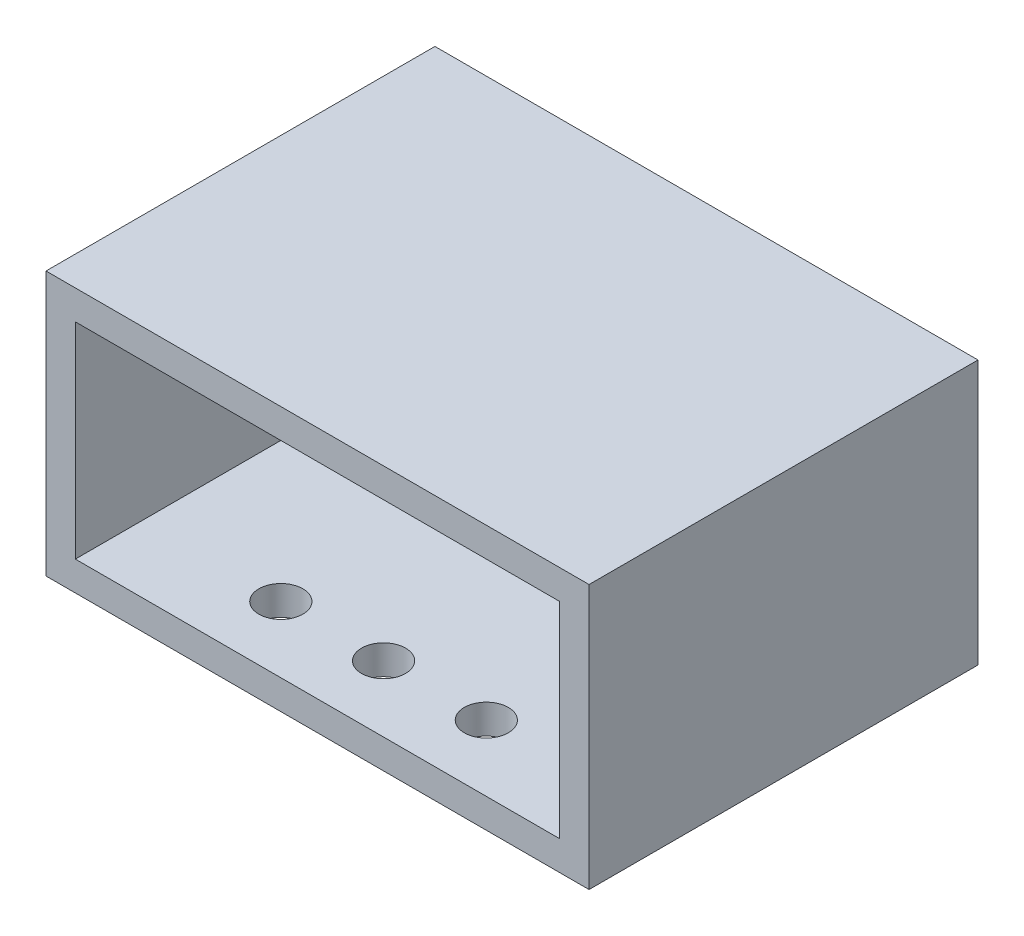
from build123d import *

# Parameters (mm, degrees)
SKIZZE1_W                       = 37
SKIZZE1_H                       = 26.5
AUFSATZ_LINEAR_AUSTRAGEN1_DEPTH = 18
SKIZZE5_W                       = 33
SKIZZE5_H                       = 14
SCHNITT_LINEAR_AUSTRAGEN1_DEPTH = 28
SKIZZE6_R                       = 1.5
SCHNITT_LINEAR_AUSTRAGEN2_DEPTH = 4


with BuildPart() as part:
    # Skizze1 → Aufsatz-Linear austragen1 (new body)
    with BuildSketch(Plane(origin=(0, 0, 0), x_dir=(1, 0, 0), z_dir=(0, 1, 0))):
        Rectangle(SKIZZE1_W, SKIZZE1_H)
    extrude(amount=AUFSATZ_LINEAR_AUSTRAGEN1_DEPTH)

    # Skizze5 → Schnitt-Linear austragen1 (cut)
    with BuildSketch(Plane(origin=(0, 0, -11.25), x_dir=(-1, 0, 0), z_dir=(0, 0, -1))):
        with Locations((0, 9)):
            Rectangle(SKIZZE5_W, SKIZZE5_H)
    extrude(amount=-SCHNITT_LINEAR_AUSTRAGEN1_DEPTH, mode=Mode.SUBTRACT)

    # Skizze6 → Schnitt-Linear austragen2 (cut, symmetric)
    with BuildSketch(Plane.XZ):
        with Locations((-7, 8.75)):
            Circle(SKIZZE6_R)
        with Locations((7, 8.75)):
            Circle(SKIZZE6_R)
        with Locations((0, 8.75)):
            Circle(SKIZZE6_R)
    schnitt_linear_austragen2 = extrude(amount=SCHNITT_LINEAR_AUSTRAGEN2_DEPTH, both=True, mode=Mode.SUBTRACT)

    # Spiegeln1: Schnitt-Linear austragen2 across plane
    add(schnitt_linear_austragen2.mirror(Plane.XY), mode=Mode.SUBTRACT)


solid = part.part
